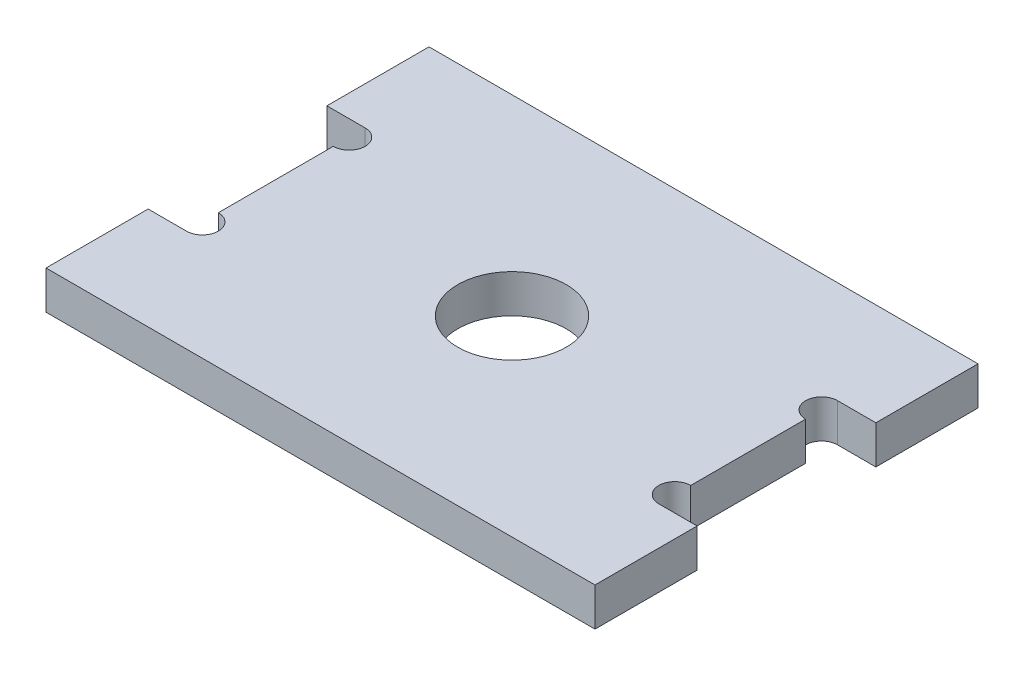
from build123d import *

# Parameters (mm, degrees)
SKETCH_1_W          = 43
SKETCH_1_H          = 30
SKETCH_1_R          = 4.25
EXTRUDE_1_DEPTH     = 3
SKETCH_2_W          = 6
SKETCH_2_H          = 14
CUT_EXTRUDE_1_DEPTH = 3
CUT_EXTRUDE_2_REACH = 5
SKETCH_3_R          = 1.25


with BuildPart() as part:
    # 草图1 → 凸台-拉伸1 (new body)
    with BuildSketch(Plane(origin=(0, 0, 0), x_dir=(1, 0, 0), z_dir=(0, 1, 0))):
        Rectangle(SKETCH_1_W, SKETCH_1_H)
        Circle(SKETCH_1_R, mode=Mode.SUBTRACT)
    extrude(amount=EXTRUDE_1_DEPTH)

    # 草图2 → 切除-拉伸1 (cut)
    with BuildSketch(Plane(origin=(0, 3, 0), x_dir=(1, 0, 0), z_dir=(0, 1, 0))):
        with Locations((21.5, 0)):
            Rectangle(SKETCH_2_W, SKETCH_2_H)
        with Locations((-21.5, 0)):
            Rectangle(SKETCH_2_W, SKETCH_2_H)
    extrude(amount=-CUT_EXTRUDE_1_DEPTH, mode=Mode.SUBTRACT)

    # 草图3 → 切除-拉伸2 (cut, up to next)
    with BuildSketch(Plane.XZ, mode=Mode.PRIVATE) as cut_extrude_2_sk1:
        with Locations((-18.5, 5.75)):
            Circle(SKETCH_3_R)
    cut_extrude_2_tool1 = extrude(cut_extrude_2_sk1.sketch, amount=-CUT_EXTRUDE_2_REACH, mode=Mode.PRIVATE) & part.part
    add(cut_extrude_2_tool1.solids().sort_by_distance((-18.5, 0, 5.75))[0], mode=Mode.SUBTRACT)
    # 草图3 → 切除-拉伸2 (cut, up to next)
    with BuildSketch(Plane.XZ, mode=Mode.PRIVATE) as cut_extrude_2_sk2:
        with Locations((-18.5, -5.75)):
            Circle(SKETCH_3_R)
    cut_extrude_2_tool2 = extrude(cut_extrude_2_sk2.sketch, amount=-CUT_EXTRUDE_2_REACH, mode=Mode.PRIVATE) & part.part
    add(cut_extrude_2_tool2.solids().sort_by_distance((-18.5, 0, -5.75))[0], mode=Mode.SUBTRACT)
    # 草图3 → 切除-拉伸2 (cut, up to next)
    with BuildSketch(Plane.XZ, mode=Mode.PRIVATE) as cut_extrude_2_sk3:
        with Locations((18.5, -5.75)):
            Circle(SKETCH_3_R)
    cut_extrude_2_tool3 = extrude(cut_extrude_2_sk3.sketch, amount=-CUT_EXTRUDE_2_REACH, mode=Mode.PRIVATE) & part.part
    add(cut_extrude_2_tool3.solids().sort_by_distance((18.5, 0, -5.75))[0], mode=Mode.SUBTRACT)
    # 草图3 → 切除-拉伸2 (cut, up to next)
    with BuildSketch(Plane.XZ, mode=Mode.PRIVATE) as cut_extrude_2_sk4:
        with Locations((18.5, 5.75)):
            Circle(SKETCH_3_R)
    cut_extrude_2_tool4 = extrude(cut_extrude_2_sk4.sketch, amount=-CUT_EXTRUDE_2_REACH, mode=Mode.PRIVATE) & part.part
    add(cut_extrude_2_tool4.solids().sort_by_distance((18.5, 0, 5.75))[0], mode=Mode.SUBTRACT)


solid = part.part
